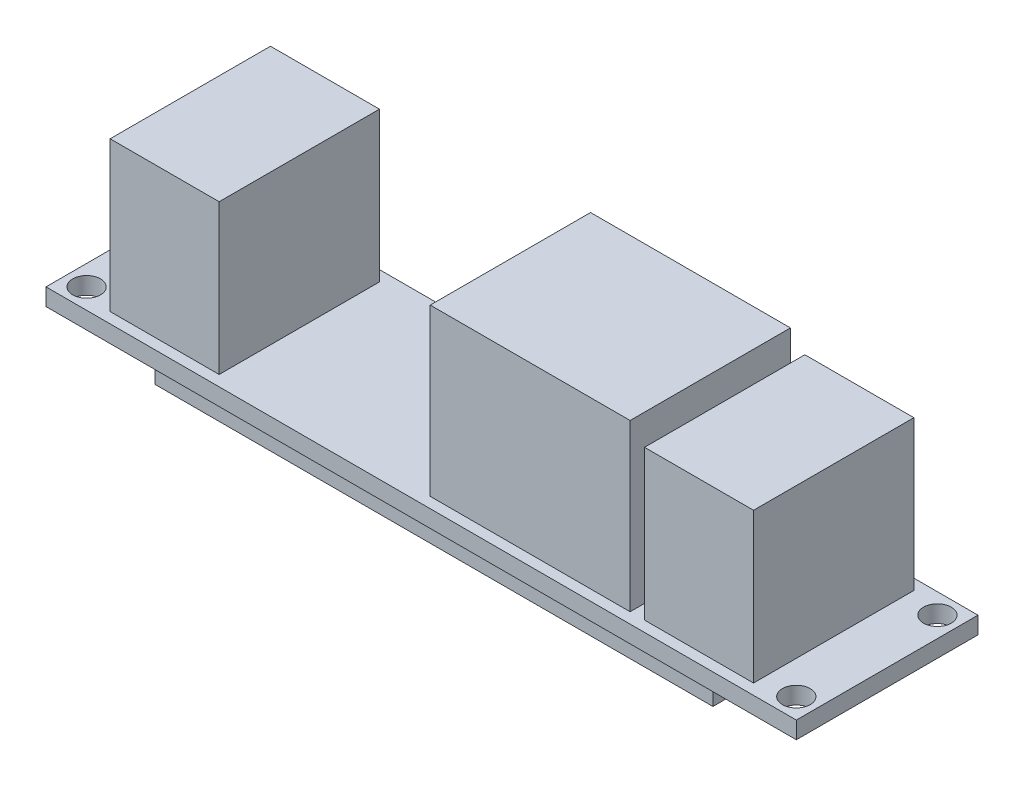
from build123d import *

# Parameters (mm, degrees)
SKETCH1_W           = 70.2
SKETCH1_H           = 17
SKETCH1_R           = 1.3
BOSS_EXTRUDE1_DEPTH = 1.6
SKETCH2_W           = 18.7
SKETCH2_H           = 15.5
SKETCH2_W_2         = 10.2
SKETCH2_H_2         = 14
BOSS_EXTRUDE2_DEPTH = 7.5
SKETCH3_W           = 52.2
SKETCH3_H           = 14.607054818
BOSS_EXTRUDE3_DEPTH = 2.4


with BuildPart() as part:
    # Sketch1 → Boss-Extrude1 (new body)
    with BuildSketch(Plane(origin=(0, 0, 0), x_dir=(1, 0, 0), z_dir=(0, 1, 0))):
        Rectangle(SKETCH1_W, SKETCH1_H)
        with Locations((-33.2, 6.6)):
            Circle(SKETCH1_R, mode=Mode.SUBTRACT)
        with Locations((33.2, 6.6)):
            Circle(SKETCH1_R, mode=Mode.SUBTRACT)
        with Locations((33.2, -6.6)):
            Circle(SKETCH1_R, mode=Mode.SUBTRACT)
        with Locations((-33.2, -6.6)):
            Circle(SKETCH1_R, mode=Mode.SUBTRACT)
    extrude(amount=-BOSS_EXTRUDE1_DEPTH)

    # Sketch2 → Boss-Extrude2 (add, symmetric)
    with BuildSketch(Plane.XY):
        with Locations((9.2, 7.75)):
            Rectangle(SKETCH2_W, SKETCH2_H)
        with Locations((25, 7)):
            Rectangle(SKETCH2_W_2, SKETCH2_H_2)
        with Locations((-25, 7)):
            Rectangle(SKETCH2_W_2, SKETCH2_H_2)
    extrude(amount=BOSS_EXTRUDE2_DEPTH, both=True)

    # Sketch3 → Boss-Extrude3 (add)
    with BuildSketch(Plane.XZ.offset(1.6)):
        Rectangle(SKETCH3_W, SKETCH3_H)
    extrude(amount=BOSS_EXTRUDE3_DEPTH)


solid = part.part
